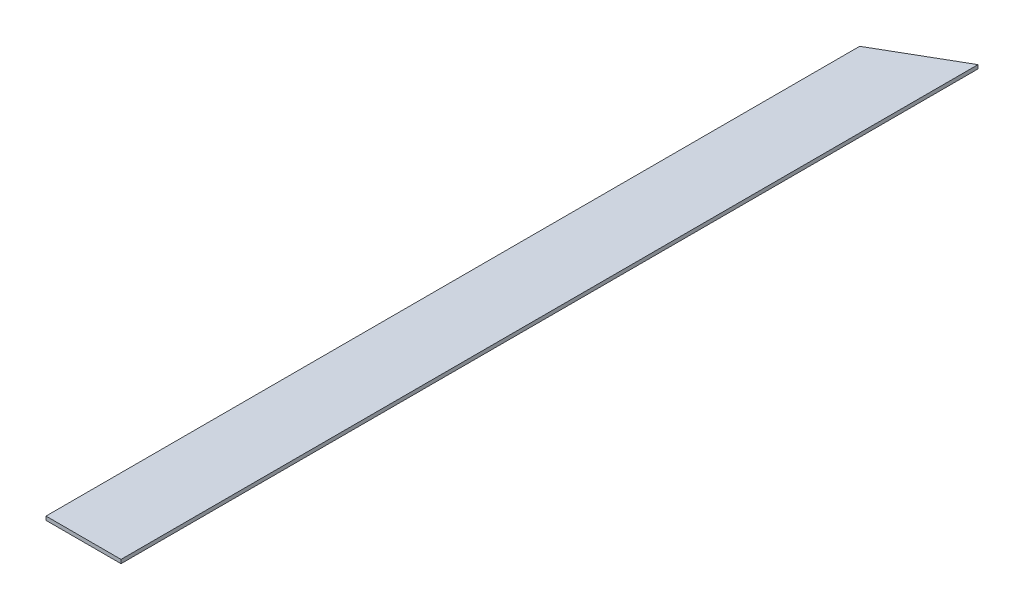
from build123d import *

# Parameters (mm, degrees)
BOSS_EXTRUDE1_DEPTH = 2.54


with BuildPart() as part:
    # Sketch1 → Boss-Extrude1 (new body)
    with BuildSketch(Plane(origin=(0, 0, 0), x_dir=(1, 0, 0), z_dir=(0, 1, 0))):
        Polygon((-25.4, 0), (25.4, 0), (25.4, 580.136), (-25.4, 550.830244956), align=None)
    extrude(amount=BOSS_EXTRUDE1_DEPTH)


solid = part.part
